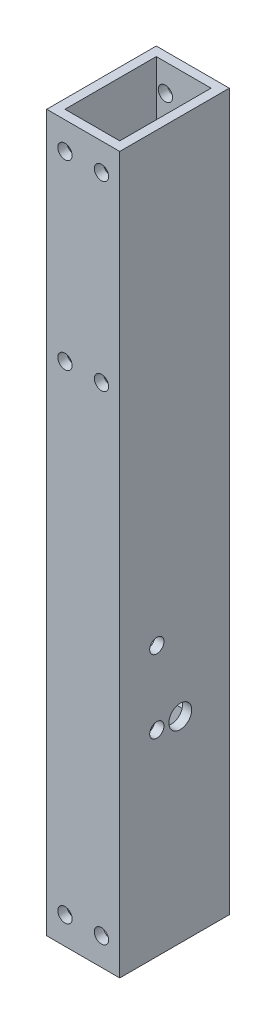
from build123d import *

# Parameters (mm, degrees)
SKETCH1_W           = 25.4
SKETCH1_H           = 38.1
SKETCH1_W_2         = 19.05
SKETCH1_H_2         = 31.75
EXTRUDE_THIN1_DEPTH = 248.92
SKETCH5_W           = 47.1424
SKETCH5_H           = 22.225
CUT_EXTRUDE2_DEPTH  = 21.082
SKETCH7_R           = 2.4892
CUT_EXTRUDE4_DEPTH  = 254.096693775
SKETCH8_R           = 2.4892
CUT_EXTRUDE5_DEPTH  = 254.096693775
SKETCH10_R          = 3.9624
CUT_EXTRUDE7_DEPTH  = 3.175
SKETCH11_R          = 3.9624
CUT_EXTRUDE8_DEPTH  = 264.09545112
SKETCH13_R          = 2.4892
CUT_EXTRUDE9_DEPTH  = 254.096693775
SKETCH16_R          = 2.4892
CUT_EXTRUDE13_DEPTH = 254.096693775


with BuildPart() as part:
    # Sketch1 → Extrude-Thin1 (new body)
    with BuildSketch(Plane(origin=(0, 0, 0), x_dir=(1, 0, 0), z_dir=(0, 1, 0))):
        with Locations((12.7, 19.05)):
            Rectangle(SKETCH1_W, SKETCH1_H)
        with Locations((12.7, 19.05)):
            Rectangle(SKETCH1_W_2, SKETCH1_H_2, mode=Mode.SUBTRACT)
    extrude(amount=EXTRUDE_THIN1_DEPTH)

    # Sketch5 → Cut-Extrude2 (cut)
    with BuildSketch(Plane.ZY):
        with Locations((-41.518281917, 68.2625)):
            Rectangle(SKETCH5_W, SKETCH5_H)
    extrude(amount=-CUT_EXTRUDE2_DEPTH, mode=Mode.SUBTRACT)

    # Sketch7 → Cut-Extrude4 (cut, through all)
    with BuildSketch(Plane.ZY):
        with Locations((-12.9032, 93.6625)):
            Circle(SKETCH7_R)
    extrude(amount=-CUT_EXTRUDE4_DEPTH, mode=Mode.SUBTRACT)

    # Sketch8 → Cut-Extrude5 (cut, through all)
    with BuildSketch(Plane.ZY):
        with Locations((-12.9032, 68.2625)):
            Circle(SKETCH8_R)
    extrude(amount=-CUT_EXTRUDE5_DEPTH, mode=Mode.SUBTRACT)

    # Sketch10 → Cut-Extrude7 (cut)
    with BuildSketch(Plane(origin=(25.4, 0, 0), x_dir=(0, 0, -1), z_dir=(1, 0, 0))):
        with Locations((21.0566, 68.2625)):
            Circle(SKETCH10_R)
    extrude(amount=-CUT_EXTRUDE7_DEPTH, mode=Mode.SUBTRACT)

    # Sketch11 → Cut-Extrude8 (cut, through all)
    with BuildSketch(Plane(origin=(76.2, 0, 0), x_dir=(0, 0, -1), z_dir=(1, 0, 0))):
        with Locations((21.0566, 68.2625)):
            Circle(SKETCH11_R)
    extrude(amount=-CUT_EXTRUDE8_DEPTH, mode=Mode.SUBTRACT)

    # Sketch13 → Cut-Extrude9 (cut, through all)
    with BuildSketch(Plane(origin=(0, 0, -38.1), x_dir=(-1, 0, 0), z_dir=(0, 0, -1))):
        with Locations((-19.05, 9.525)):
            Circle(SKETCH13_R)
        with Locations((-6.35, 9.525)):
            Circle(SKETCH13_R)
        with Locations((-6.35, 239.395)):
            Circle(SKETCH13_R)
        with Locations((-19.05, 239.395)):
            Circle(SKETCH13_R)
    extrude(amount=-CUT_EXTRUDE9_DEPTH, mode=Mode.SUBTRACT)

    # Sketch16 → Cut-Extrude13 (cut, through all)
    with BuildSketch(Plane(origin=(0, 0, -38.1), x_dir=(-1, 0, 0), z_dir=(0, 0, -1))):
        with Locations((-19.05, 176.15465)):
            Circle(SKETCH16_R)
        with Locations((-6.35, 176.15465)):
            Circle(SKETCH16_R)
    extrude(amount=-CUT_EXTRUDE13_DEPTH, mode=Mode.SUBTRACT)


solid = part.part
